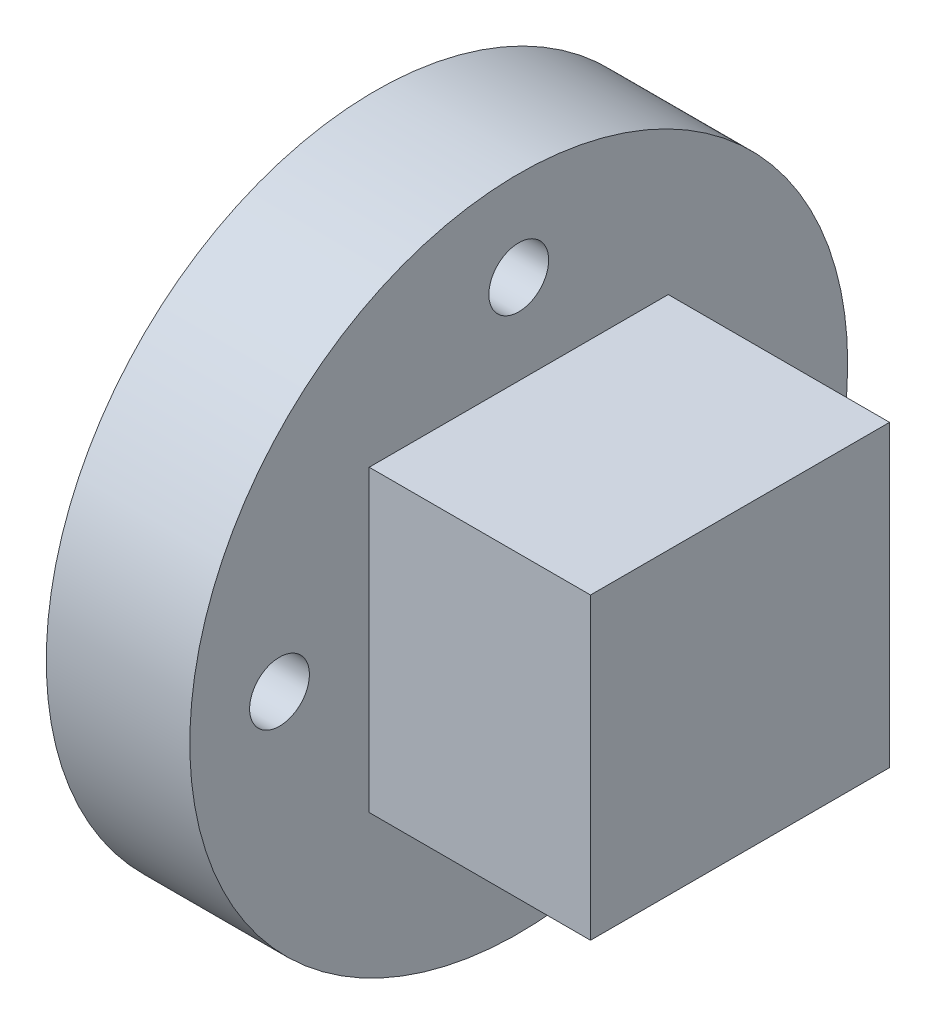
from build123d import *

# Parameters (mm, degrees)
SKETCH1_R           = 5.5
SKETCH1_R_2         = 0.5
BOSS_EXTRUDE1_DEPTH = 6
SKETCH2_R           = 5.5
BOSS_EXTRUDE2_DEPTH = 1
SKETCH3_R           = 0.5
CUT_EXTRUDE1_DEPTH  = 7
SKETCH4_W           = 5
SKETCH4_H           = 5
BOSS_EXTRUDE3_DEPTH = 0.1
SKETCH5_OUTSIDE_W   = 16.342
SKETCH5_OUTSIDE_H   = 16.342
SKETCH5_OUTSIDE_W_2 = 5
SKETCH5_OUTSIDE_H_2 = 5
CUT_EXTRUDE2_DEPTH  = 3.6


with BuildPart() as part:
    # Sketch1 → Boss-Extrude1 (new body)
    with BuildSketch(Plane(origin=(0, 0, 0), x_dir=(0, 0, -1), z_dir=(1, 0, 0))):
        Circle(SKETCH1_R)
        with Locations((0, 4)):
            Circle(SKETCH1_R_2, mode=Mode.SUBTRACT)
        with Locations((4, 0)):
            Circle(SKETCH1_R_2, mode=Mode.SUBTRACT)
        with Locations((0, -4)):
            Circle(SKETCH1_R_2, mode=Mode.SUBTRACT)
        with Locations((-4, 0)):
            Circle(SKETCH1_R_2, mode=Mode.SUBTRACT)
        with BuildLine():
            Line((-1.321221026, 1.6), (1.321221026, 1.6))
            ThreePointArc((1.321221026, 1.6), (0, -2.075), (-1.321221026, 1.6))
        make_face(mode=Mode.SUBTRACT)
    extrude(amount=BOSS_EXTRUDE1_DEPTH)

    # Sketch2 → Boss-Extrude2 (add)
    with BuildSketch(Plane(origin=(6, 0, 0), x_dir=(0, 0, -1), z_dir=(1, 0, 0))):
        Circle(SKETCH2_R)
    extrude(amount=-BOSS_EXTRUDE2_DEPTH)

    # Sketch3 → Cut-Extrude1 (cut, through all)
    with BuildSketch(Plane.ZY):
        with Locations((0, 4)):
            Circle(SKETCH3_R)
        with Locations((4, 0)):
            Circle(SKETCH3_R)
        with Locations((0, -4)):
            Circle(SKETCH3_R)
        with Locations((-4, 0)):
            Circle(SKETCH3_R)
    extrude(amount=-CUT_EXTRUDE1_DEPTH, mode=Mode.SUBTRACT)

    # Sketch4 → Boss-Extrude3 (add)
    with BuildSketch(Plane(origin=(6, 0, 0), x_dir=(0, 0, -1), z_dir=(1, 0, 0))):
        Rectangle(SKETCH4_W, SKETCH4_H)
    extrude(amount=BOSS_EXTRUDE3_DEPTH)

    # Sketch5 outside → Cut-Extrude2 (cut)
    with BuildSketch(Plane(origin=(6, 0, 0), x_dir=(0, 0, -1), z_dir=(1, 0, 0))):
        Rectangle(SKETCH5_OUTSIDE_W, SKETCH5_OUTSIDE_H)
        Rectangle(SKETCH5_OUTSIDE_W_2, SKETCH5_OUTSIDE_H_2, mode=Mode.SUBTRACT)
    extrude(amount=-CUT_EXTRUDE2_DEPTH, mode=Mode.SUBTRACT)


solid = part.part
